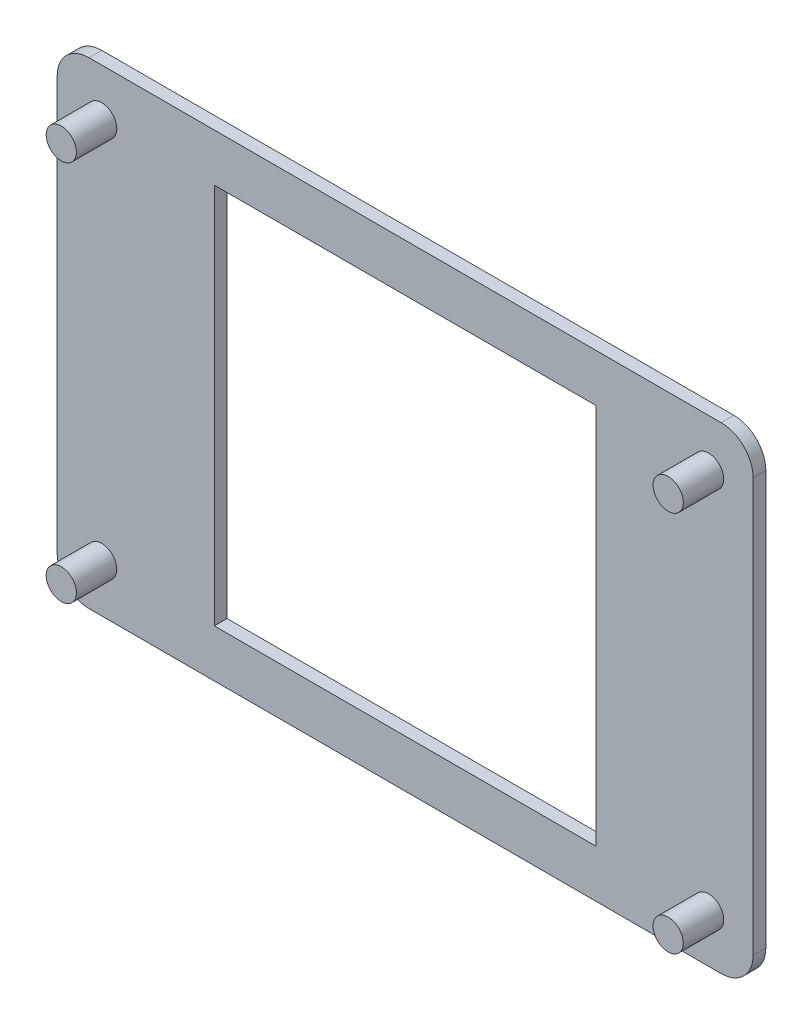
from build123d import *

# Parameters (mm, degrees)
SKETCH1_W           = 109.3978
SKETCH1_H           = 75
BOSS_EXTRUDE1_DEPTH = 2
SKETCH2_R           = 2.375
BOSS_EXTRUDE2_DEPTH = 6.35
CUT_EXTRUDE1_REACH  = 4
SKETCH3_W           = 60
SKETCH3_H           = 60
FILLET1_R           = 5


with BuildPart() as part:
    # Sketch1 → Boss-Extrude1 (new body)
    with BuildSketch(Plane.XY):
        with Locations((54.6989, 37.5)):
            Rectangle(SKETCH1_W, SKETCH1_H)
    extrude(amount=BOSS_EXTRUDE1_DEPTH)

    # Sketch2 → Boss-Extrude2 (add)
    with BuildSketch(Plane.XY.offset(2)):
        with Locations((6.9977, 67.4974)):
            Circle(SKETCH2_R)
        with Locations((102.4001, 67.4974)):
            Circle(SKETCH2_R)
        with Locations((102.4001, 7.5026)):
            Circle(SKETCH2_R)
        with Locations((6.9977, 7.5026)):
            Circle(SKETCH2_R)
    extrude(amount=BOSS_EXTRUDE2_DEPTH)

    # Sketch3 → Cut-Extrude1 (cut, up to next)
    with BuildSketch(Plane.XY.offset(2), mode=Mode.PRIVATE) as cut_extrude1_sk1:
        with Locations((54.6989, 37.5)):
            Rectangle(SKETCH3_W, SKETCH3_H)
    cut_extrude1_tool1 = extrude(cut_extrude1_sk1.sketch, amount=-CUT_EXTRUDE1_REACH, mode=Mode.PRIVATE) & part.part
    add(cut_extrude1_tool1.solids().sort_by_distance((54.6989, 37.5, 2))[0], mode=Mode.SUBTRACT)

    # Fillet1
    fillet1_edges = [part.edges().sort_by_distance(p)[0] for p in [
        (0, 75, 1),
        (109.3978, 75, 1),
        (109.3978, 0, 1),
        (0, 0, 1),
    ]]
    fillet(fillet1_edges, radius=FILLET1_R)


solid = part.part
